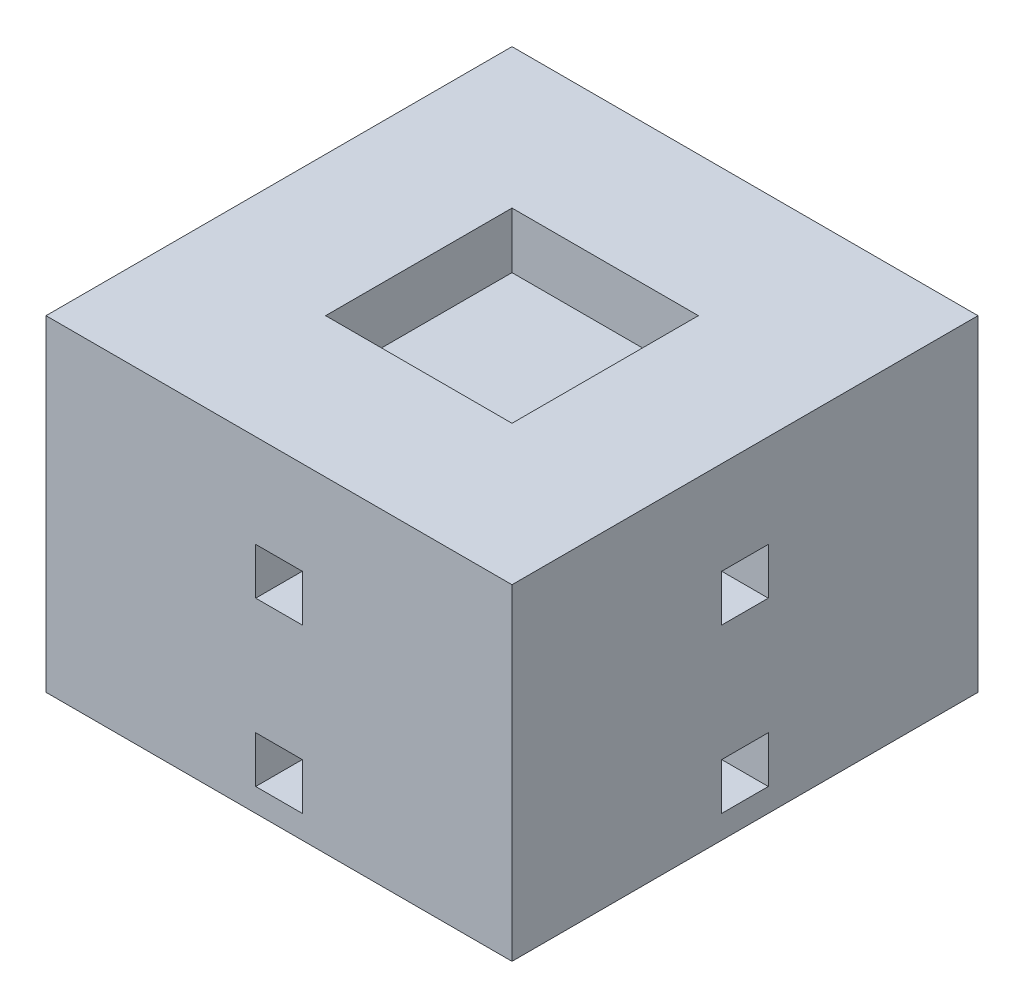
from build123d import *

# Parameters (mm, degrees)
SKETCH1_W           = 50
SKETCH1_H           = 50
BOSS_EXTRUDE1_DEPTH = 35
SKETCH3_W           = 5
SKETCH3_H           = 5
CUT_EXTRUDE2_DEPTH  = 6
SKETCH4_W           = 5
SKETCH4_H           = 5
CUT_EXTRUDE3_DEPTH  = 5
SKETCH5_W           = 5
SKETCH5_H           = 5
CUT_EXTRUDE4_DEPTH  = 6
SKETCH6_W           = 5
SKETCH6_H           = 5
CUT_EXTRUDE5_DEPTH  = 6
SKETCH7_W           = 20
SKETCH7_H           = 20
CUT_EXTRUDE6_DEPTH  = 6
SKETCH8_W           = 20
SKETCH8_H           = 20
CUT_EXTRUDE7_DEPTH  = 6


with BuildPart() as part:
    # Sketch1 → Boss-Extrude1 (new body)
    with BuildSketch(Plane(origin=(0, 0, 0), x_dir=(1, 0, 0), z_dir=(0, 1, 0))):
        Rectangle(SKETCH1_W, SKETCH1_H)
    extrude(amount=BOSS_EXTRUDE1_DEPTH)

    # Sketch3 → Cut-Extrude2 (cut)
    with BuildSketch(Plane.ZY.offset(25)):
        with Locations((0, 5)):
            Rectangle(SKETCH3_W, SKETCH3_H)
        with Locations((0, 22.5)):
            Rectangle(SKETCH3_W, SKETCH3_H)
    extrude(amount=-CUT_EXTRUDE2_DEPTH, mode=Mode.SUBTRACT)

    # Sketch4 → Cut-Extrude3 (cut)
    with BuildSketch(Plane(origin=(0, 0, -25), x_dir=(-1, 0, 0), z_dir=(0, 0, -1))):
        with Locations((0, 5)):
            Rectangle(SKETCH4_W, SKETCH4_H)
        with Locations((0, 22.5)):
            Rectangle(SKETCH4_W, SKETCH4_H)
    extrude(amount=-CUT_EXTRUDE3_DEPTH, mode=Mode.SUBTRACT)

    # Sketch5 → Cut-Extrude4 (cut)
    with BuildSketch(Plane(origin=(25, 0, 0), x_dir=(0, 0, -1), z_dir=(1, 0, 0))):
        with Locations((0, 5)):
            Rectangle(SKETCH5_W, SKETCH5_H)
        with Locations((0, 22.5)):
            Rectangle(SKETCH5_W, SKETCH5_H)
    extrude(amount=-CUT_EXTRUDE4_DEPTH, mode=Mode.SUBTRACT)

    # Sketch6 → Cut-Extrude5 (cut)
    with BuildSketch(Plane.XY.offset(25)):
        with Locations((0, 5)):
            Rectangle(SKETCH6_W, SKETCH6_H)
        with Locations((0, 22.5)):
            Rectangle(SKETCH6_W, SKETCH6_H)
    extrude(amount=-CUT_EXTRUDE5_DEPTH, mode=Mode.SUBTRACT)

    # Sketch7 → Cut-Extrude6 (cut)
    with BuildSketch(Plane(origin=(0, 0, 0), x_dir=(-1, 0, 0), z_dir=(0, -1, 0))):
        Rectangle(SKETCH7_W, SKETCH7_H)
    extrude(amount=-CUT_EXTRUDE6_DEPTH, mode=Mode.SUBTRACT)

    # Sketch8 → Cut-Extrude7 (cut)
    with BuildSketch(Plane(origin=(0, 35, 0), x_dir=(1, 0, 0), z_dir=(0, 1, 0))):
        Rectangle(SKETCH8_W, SKETCH8_H)
    extrude(amount=-CUT_EXTRUDE7_DEPTH, mode=Mode.SUBTRACT)


solid = part.part
